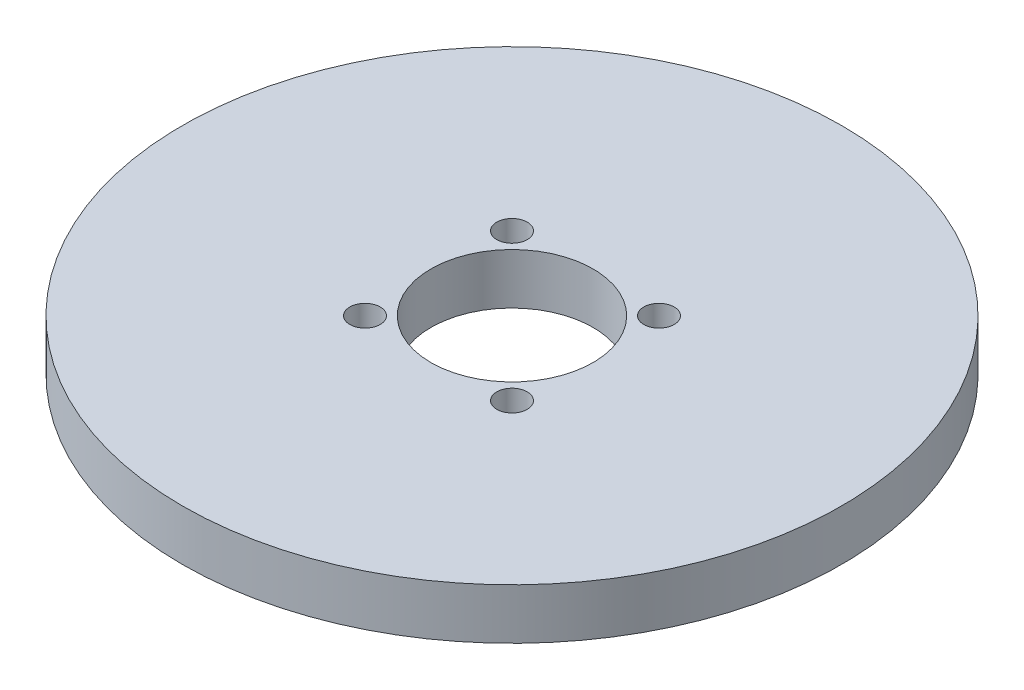
from build123d import *

# Parameters (mm, degrees)
SKETCH1_R           = 32.5
SKETCH1_R_2         = 8
SKETCH1_R_3         = 1.5
BOSS_EXTRUDE1_DEPTH = 5


with BuildPart() as part:
    # Sketch1 → Boss-Extrude1 (new body)
    with BuildSketch(Plane(origin=(0, 0, 0), x_dir=(1, 0, 0), z_dir=(0, 1, 0))):
        Circle(SKETCH1_R)
        Circle(SKETCH1_R_2, mode=Mode.SUBTRACT)
        with Locations((-7.247844507, 7.247844507)):
            Circle(SKETCH1_R_3, mode=Mode.SUBTRACT)
        with Locations((7.247844507, 7.247844507)):
            Circle(SKETCH1_R_3, mode=Mode.SUBTRACT)
        with Locations((7.247844507, -7.247844507)):
            Circle(SKETCH1_R_3, mode=Mode.SUBTRACT)
        with Locations((-7.247844507, -7.247844507)):
            Circle(SKETCH1_R_3, mode=Mode.SUBTRACT)
    extrude(amount=BOSS_EXTRUDE1_DEPTH)


solid = part.part
